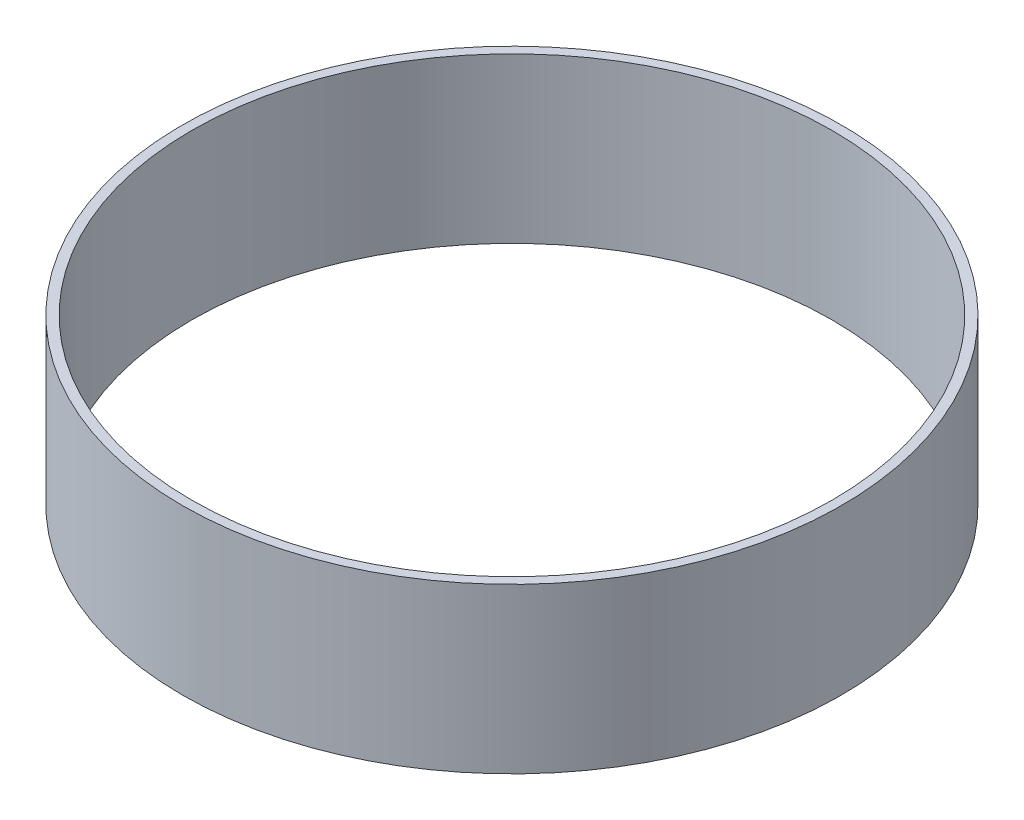
from build123d import *

# Parameters (mm, degrees)
SKETCH1_R           = 51
SKETCH1_R_2         = 49.55
BOSS_EXTRUDE1_DEPTH = 25.4


with BuildPart() as part:
    # Sketch1 → Boss-Extrude1 (new body)
    with BuildSketch(Plane(origin=(0, 0, 0), x_dir=(1, 0, 0), z_dir=(0, 1, 0))):
        Circle(SKETCH1_R)
        Circle(SKETCH1_R_2, mode=Mode.SUBTRACT)
    extrude(amount=BOSS_EXTRUDE1_DEPTH)


solid = part.part
